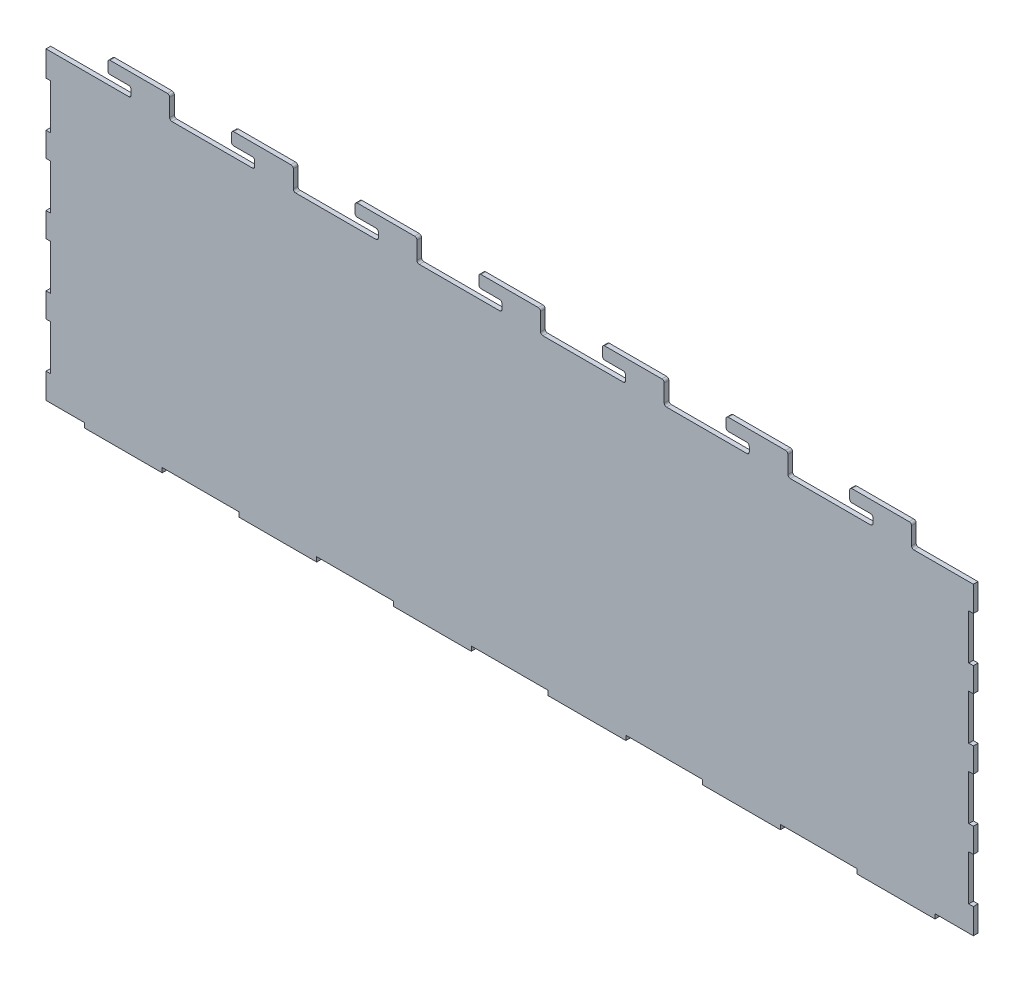
from build123d import *

# Parameters (mm, degrees)
CROQUIS1_W              = 600
CROQUIS1_H              = 200
SALIENTE_EXTRUIR1_DEPTH = 3
CROQUIS2_W              = 3
CROQUIS2_H              = 29.2
CROQUIS2_W_2            = 24.85
CROQUIS2_H_2            = 3
CROQUIS2_W_3            = 49.7
CORTAR_EXTRUIR1_DEPTH   = 4
SALIENTE_EXTRUIR2_DEPTH = 3
REDONDEO1_R             = 1.5


with BuildPart() as part:
    # Croquis1 → Saliente-Extruir1 (new body)
    with BuildSketch(Plane.XY):
        Rectangle(CROQUIS1_W, CROQUIS1_H)
    extrude(amount=SALIENTE_EXTRUIR1_DEPTH)

    # Croquis2 → Cortar-Extruir1 (cut, through all)
    with BuildSketch(Plane(origin=(0, 0, 0), x_dir=(-1, 0, 0), z_dir=(0, 0, -1))):
        with Locations((-298.5, 69)):
            Rectangle(CROQUIS2_W, CROQUIS2_H)
        with Locations((298.5, 69)):
            Rectangle(CROQUIS2_W, CROQUIS2_H)
        with Locations((-298.5, 24)):
            Rectangle(CROQUIS2_W, CROQUIS2_H)
        with Locations((298.5, 24)):
            Rectangle(CROQUIS2_W, CROQUIS2_H)
        with Locations((-298.5, -21)):
            Rectangle(CROQUIS2_W, CROQUIS2_H)
        with Locations((298.5, -21)):
            Rectangle(CROQUIS2_W, CROQUIS2_H)
        with Locations((-298.5, -66)):
            Rectangle(CROQUIS2_W, CROQUIS2_H)
        with Locations((298.5, -66)):
            Rectangle(CROQUIS2_W, CROQUIS2_H)
        with Locations((-287.575, -98.5)):
            Rectangle(CROQUIS2_W_2, CROQUIS2_H_2)
        with Locations((287.575, -98.5)):
            Rectangle(CROQUIS2_W_2, CROQUIS2_H_2)
        with Locations((-200, -98.5)):
            Rectangle(CROQUIS2_W_3, CROQUIS2_H_2)
        with Locations((200, -98.5)):
            Rectangle(CROQUIS2_W_3, CROQUIS2_H_2)
        with Locations((-100, -98.5)):
            Rectangle(CROQUIS2_W_3, CROQUIS2_H_2)
        with Locations((100, -98.5)):
            Rectangle(CROQUIS2_W_3, CROQUIS2_H_2)
        with Locations((0, -98.5)):
            Rectangle(CROQUIS2_W_3, CROQUIS2_H_2)
    extrude(amount=-CORTAR_EXTRUIR1_DEPTH, mode=Mode.SUBTRACT)

    # Croquis3 → Saliente-Extruir2 (add)
    with BuildSketch(Plane(origin=(0, 0, 0), x_dir=(-1, 0, 0), z_dir=(0, 0, -1))):
        with BuildLine():
            Line((-235, 100), (-235, 104.8))
            ThreePointArc((-235, 104.8), (-234.560660172, 105.860660172), (-233.5, 106.3))
            Line((-233.5, 106.3), (-221.5, 106.3))
            ThreePointArc((-221.5, 106.3), (-220.439339828, 106.739339828), (-220, 107.8))
            Line((-220, 107.8), (-220, 112.8))
            ThreePointArc((-220, 112.8), (-220.439339828, 113.860660172), (-221.5, 114.3))
            Line((-221.5, 114.3), (-258.5, 114.3))
            ThreePointArc((-258.5, 114.3), (-259.560660172, 113.860660172), (-260, 112.8))
            Line((-260, 112.8), (-260, 100))
            Line((-260, 100), (-235, 100))
        make_face()
        with BuildLine():
            Line((-180, 100), (-155, 100))
            Line((-155, 100), (-155, 104.8))
            ThreePointArc((-155, 104.8), (-154.560660172, 105.860660172), (-153.5, 106.3))
            Line((-153.5, 106.3), (-141.5, 106.3))
            ThreePointArc((-141.5, 106.3), (-140.439339828, 106.739339828), (-140, 107.8))
            Line((-140, 107.8), (-140, 112.8))
            ThreePointArc((-140, 112.8), (-140.439339828, 113.860660172), (-141.5, 114.3))
            Line((-141.5, 114.3), (-178.5, 114.3))
            ThreePointArc((-178.5, 114.3), (-179.560660172, 113.860660172), (-180, 112.8))
            Line((-180, 112.8), (-180, 100))
        make_face()
        with BuildLine():
            Line((-100, 100), (-75, 100))
            Line((-75, 100), (-75, 104.8))
            ThreePointArc((-75, 104.8), (-74.560660172, 105.860660172), (-73.5, 106.3))
            Line((-73.5, 106.3), (-61.5, 106.3))
            ThreePointArc((-61.5, 106.3), (-60.439339828, 106.739339828), (-60, 107.8))
            Line((-60, 107.8), (-60, 112.8))
            ThreePointArc((-60, 112.8), (-60.439339828, 113.860660172), (-61.5, 114.3))
            Line((-61.5, 114.3), (-98.5, 114.3))
            ThreePointArc((-98.5, 114.3), (-99.560660172, 113.860660172), (-100, 112.8))
            Line((-100, 112.8), (-100, 100))
        make_face()
        with BuildLine():
            Line((-20, 100), (5, 100))
            Line((5, 100), (5, 104.8))
            ThreePointArc((5, 104.8), (5.439339828, 105.860660172), (6.5, 106.3))
            Line((6.5, 106.3), (18.5, 106.3))
            ThreePointArc((18.5, 106.3), (19.560660172, 106.739339828), (20, 107.8))
            Line((20, 107.8), (20, 112.8))
            ThreePointArc((20, 112.8), (19.560660172, 113.860660172), (18.5, 114.3))
            Line((18.5, 114.3), (-18.5, 114.3))
            ThreePointArc((-18.5, 114.3), (-19.560660172, 113.860660172), (-20, 112.8))
            Line((-20, 112.8), (-20, 100))
        make_face()
        with BuildLine():
            Line((60, 100), (85, 100))
            Line((85, 100), (85, 104.8))
            ThreePointArc((85, 104.8), (85.439339828, 105.860660172), (86.5, 106.3))
            Line((86.5, 106.3), (98.5, 106.3))
            ThreePointArc((98.5, 106.3), (99.560660172, 106.739339828), (100, 107.8))
            Line((100, 107.8), (100, 112.8))
            ThreePointArc((100, 112.8), (99.560660172, 113.860660172), (98.5, 114.3))
            Line((98.5, 114.3), (61.5, 114.3))
            ThreePointArc((61.5, 114.3), (60.439339828, 113.860660172), (60, 112.8))
            Line((60, 112.8), (60, 100))
        make_face()
        with BuildLine():
            Line((140, 100), (165, 100))
            Line((165, 100), (165, 104.8))
            ThreePointArc((165, 104.8), (165.439339828, 105.860660172), (166.5, 106.3))
            Line((166.5, 106.3), (178.5, 106.3))
            ThreePointArc((178.5, 106.3), (179.560660172, 106.739339828), (180, 107.8))
            Line((180, 107.8), (180, 112.8))
            ThreePointArc((180, 112.8), (179.560660172, 113.860660172), (178.5, 114.3))
            Line((178.5, 114.3), (141.5, 114.3))
            ThreePointArc((141.5, 114.3), (140.439339828, 113.860660172), (140, 112.8))
            Line((140, 112.8), (140, 100))
        make_face()
        with BuildLine():
            Line((220, 100), (245, 100))
            Line((245, 100), (245, 104.8))
            ThreePointArc((245, 104.8), (245.439339828, 105.860660172), (246.5, 106.3))
            Line((246.5, 106.3), (258.5, 106.3))
            ThreePointArc((258.5, 106.3), (259.560660172, 106.739339828), (260, 107.8))
            Line((260, 107.8), (260, 112.8))
            ThreePointArc((260, 112.8), (259.560660172, 113.860660172), (258.5, 114.3))
            Line((258.5, 114.3), (221.5, 114.3))
            ThreePointArc((221.5, 114.3), (220.439339828, 113.860660172), (220, 112.8))
            Line((220, 112.8), (220, 100))
        make_face()
    extrude(amount=-SALIENTE_EXTRUIR2_DEPTH)

    # Redondeo1
    redondeo1_edges = [part.edges().sort_by_distance(p)[0] for p in [
        (235, 100, 1.5),
        (260, 100, 1.5),
        (155, 100, 1.5),
        (180, 100, 1.5),
        (75, 100, 1.5),
        (100, 100, 1.5),
        (-5, 100, 1.5),
        (20, 100, 1.5),
        (-85, 100, 1.5),
        (-60, 100, 1.5),
        (-165, 100, 1.5),
        (-140, 100, 1.5),
        (-245, 100, 1.5),
        (-220, 100, 1.5),
    ]]
    fillet(redondeo1_edges, radius=REDONDEO1_R)


solid = part.part
